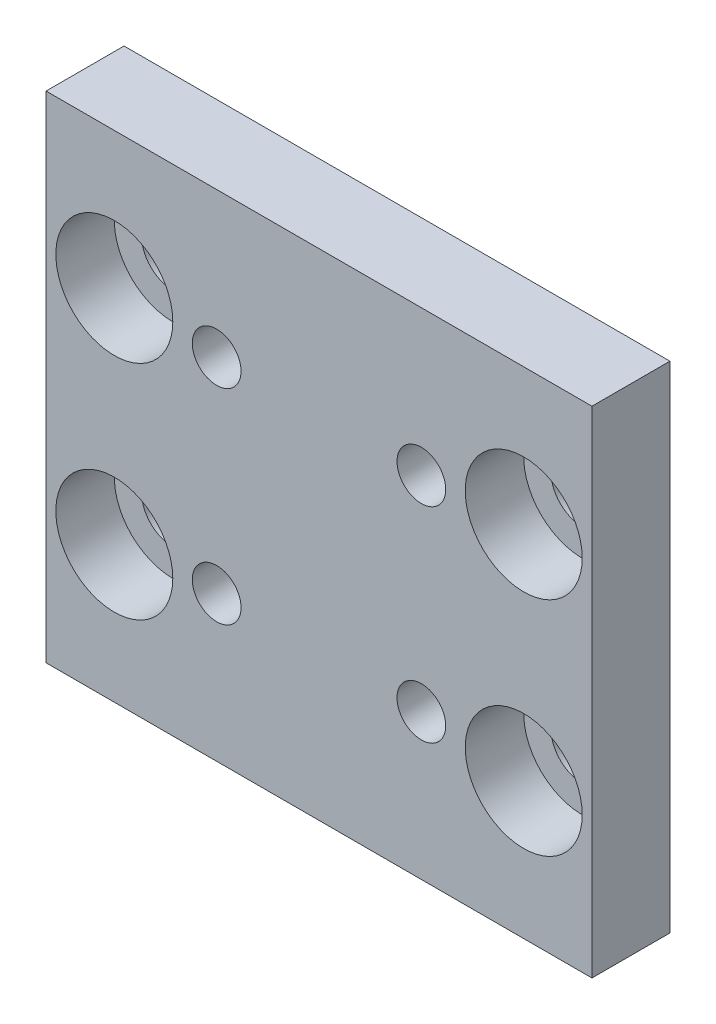
from build123d import *

# Parameters (mm, degrees)
SKETCH1_W           = 28
SKETCH1_H           = 25.4
SKETCH1_R           = 1.25
SKETCH1_R_2         = 1.6
BOSS_EXTRUDE1_DEPTH = 4
SKETCH2_R           = 3
CUT_EXTRUDE1_DEPTH  = 3


with BuildPart() as part:
    # Sketch1 → Boss-Extrude1 (new body)
    with BuildSketch(Plane.XY):
        with Locations((14, 12.7)):
            Rectangle(SKETCH1_W, SKETCH1_H)
        with Locations((8.75, 17.95)):
            Circle(SKETCH1_R, mode=Mode.SUBTRACT)
        with Locations((19.25, 17.95)):
            Circle(SKETCH1_R, mode=Mode.SUBTRACT)
        with Locations((19.25, 7.45)):
            Circle(SKETCH1_R, mode=Mode.SUBTRACT)
        with Locations((8.75, 7.45)):
            Circle(SKETCH1_R, mode=Mode.SUBTRACT)
        with Locations((3.5, 18.4)):
            Circle(SKETCH1_R_2, mode=Mode.SUBTRACT)
        with Locations((3.5, 7)):
            Circle(SKETCH1_R_2, mode=Mode.SUBTRACT)
        with Locations((24.5, 7)):
            Circle(SKETCH1_R_2, mode=Mode.SUBTRACT)
        with Locations((24.5, 18.4)):
            Circle(SKETCH1_R_2, mode=Mode.SUBTRACT)
    extrude(amount=BOSS_EXTRUDE1_DEPTH)

    # Sketch2 → Cut-Extrude1 (cut)
    with BuildSketch(Plane.XY.offset(4)):
        with Locations((24.5, 18.4)):
            Circle(SKETCH2_R)
        with Locations((3.5, 18.4)):
            Circle(SKETCH2_R)
        with Locations((3.5, 7)):
            Circle(SKETCH2_R)
        with Locations((24.5, 7)):
            Circle(SKETCH2_R)
    extrude(amount=-CUT_EXTRUDE1_DEPTH, mode=Mode.SUBTRACT)


solid = part.part
